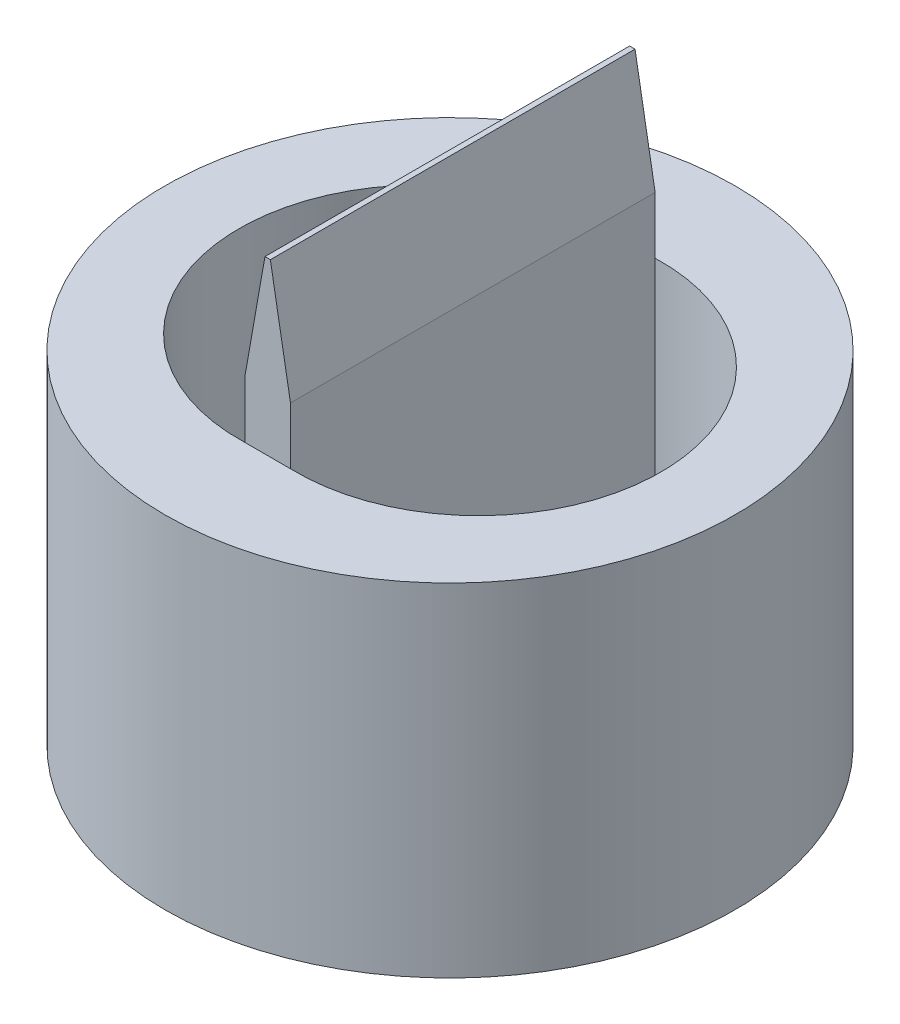
from build123d import *

# Parameters (mm, degrees)
SKETCH_1_R             = 5
EXTRUDE_1_DEPTH        = 6
CUT_EXTRUDE_1_DEPTH    = 4
SKETCH_3_W             = 0.8
SKETCH_3_H             = 6.396892992
EXTRUDE_2_DEPTH        = 3
CHAMFER_1_SIZE         = 2
CHAMFER_1_SIZE2        = 0.352653961
CHAMFER_1_PART_2_SIZE  = 2
CHAMFER_1_PART_2_SIZE2 = 0.352653961


with BuildPart() as part:
    # Эскиз1 → Бобышка-Вытянуть1 (new body)
    with BuildSketch(Plane(origin=(0, 0, 0), x_dir=(1, 0, 0), z_dir=(0, 1, 0))):
        with Locations(Location((0, 0, 0), (0, 0, 270))):  # turned: the seam where the file's is
            Circle(SKETCH_1_R)
    extrude(amount=EXTRUDE_1_DEPTH)

    # Эскиз2 → Вырез-Вытянуть1 (cut)
    with BuildSketch(Plane(origin=(0, 6, 0), x_dir=(1, 0, 0), z_dir=(0, 1, 0))):
        with BuildLine():
            Line((-0.4, 3.198446496), (-0.4, -3.198446496))
            ThreePointArc((-0.4, -3.198446496), (-3.699699625, 0), (-0.4, 3.198446496))
        make_face()
        with BuildLine():
            Line((0.4, -3.198446496), (0.4, 3.198446496))
            ThreePointArc((0.4, 3.198446496), (3.699699625, 0), (0.4, -3.198446496))
        make_face()
    extrude(amount=-CUT_EXTRUDE_1_DEPTH, mode=Mode.SUBTRACT)

    # Эскиз3 → Бобышка-Вытянуть2 (add)
    with BuildSketch(Plane(origin=(0, 6, 0), x_dir=(1, 0, 0), z_dir=(0, 1, 0))):
        Rectangle(SKETCH_3_W, SKETCH_3_H)
    extrude(amount=EXTRUDE_2_DEPTH)

    # Фаска1
    chamfer_1_edges = [part.edges().sort_by_distance(p)[0] for p in [
        (0.4, 9, 0),
    ]]
    chamfer_1_side = [part.faces().sort_by_distance(p)[0] for p in [
        (0.4, 5.5, 0),
    ]]
    chamfer(chamfer_1_edges, length=CHAMFER_1_SIZE, length2=CHAMFER_1_SIZE2, reference=chamfer_1_side[0])

    # Фаска1 part 2
    chamfer_1_part_2_edges = [part.edges().sort_by_distance(p)[0] for p in [
        (-0.4, 9, 0),
    ]]
    chamfer_1_part_2_side = [part.faces().sort_by_distance(p)[0] for p in [
        (-0.4, 5.5, 0),
    ]]
    chamfer(chamfer_1_part_2_edges, length=CHAMFER_1_PART_2_SIZE, length2=CHAMFER_1_PART_2_SIZE2, reference=chamfer_1_part_2_side[0])


solid = part.part
